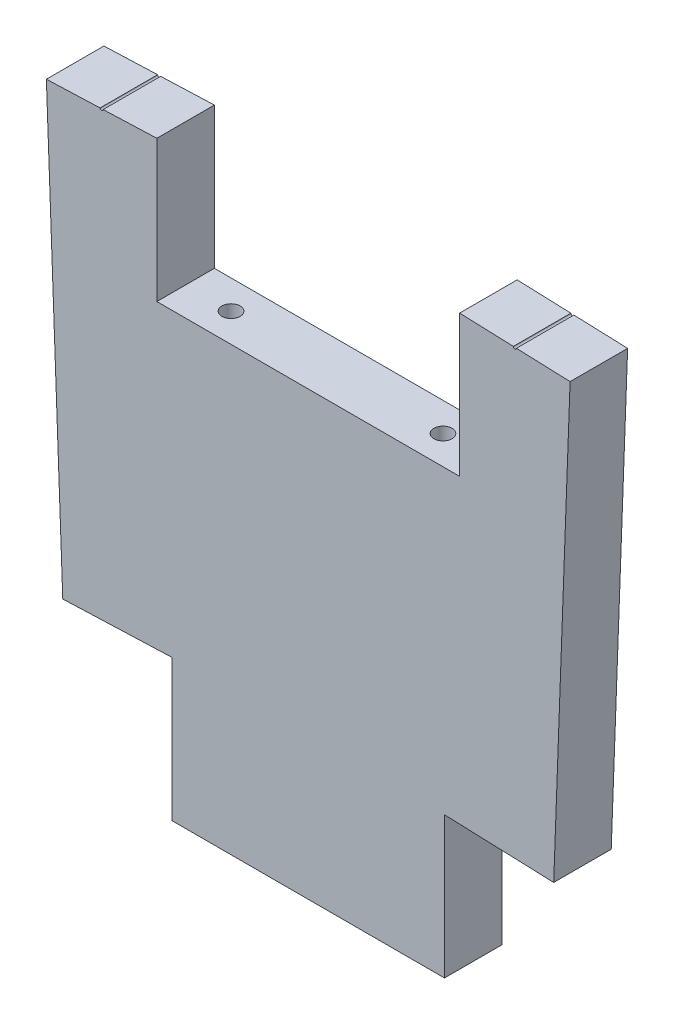
from build123d import *

# Parameters (mm, degrees)
BOSS_EXTRUDE1_DEPTH = 19
CUT_EXTRUDE1_DEPTH  = 19
SKETCH6_R           = 3
CUT_EXTRUDE2_DEPTH  = 10
SKETCH9_R           = 0.5
CUT_EXTRUDE3_DEPTH  = 20


with BuildPart() as part:
    # Sketch2 → Boss-Extrude1 (new body)
    with BuildSketch(Plane.XY):
        Polygon((-50, -12.7), (50, -12.7), (50, 34.001988406), (86.488954477, 32.648136171), (79.389661188, -158.69164437), (-79.389661188, -158.69164437), (-86.488954477, 32.648136171), (-50, 34.001988406), align=None)
    extrude(amount=-BOSS_EXTRUDE1_DEPTH)

    # Sketch4 → Cut-Extrude1 (cut)
    with BuildSketch(Plane(origin=(0, 0, -19), x_dir=(-1, 0, 0), z_dir=(0, 0, -1))):
        Polygon((176.999986596, -116.887260719), (45, -111.989655964), (45, -158.69164437), (-45, -158.69164437), (-45, -111.989655964), (-160.814787096, -116.286740127), (-160.814787096, -226.328943165), (176.999986596, -226.328943165), align=None)
    extrude(amount=-CUT_EXTRUDE1_DEPTH, mode=Mode.SUBTRACT)

    # Sketch6 → Cut-Extrude2 (cut)
    with BuildSketch(Plane(origin=(0, -12.7, 0), x_dir=(1, 0, 0), z_dir=(0, 1, 0))):
        with Locations((35, 9.5)):
            Circle(SKETCH6_R)
        with Locations((-35, 9.5)):
            Circle(SKETCH6_R)
    extrude(amount=-CUT_EXTRUDE2_DEPTH, mode=Mode.SUBTRACT)

    # Sketch9 → Cut-Extrude3 (cut)
    with BuildSketch(Plane(origin=(0, 0, -19), x_dir=(-1, 0, 0), z_dir=(0, 0, -1))):
        with Locations((68.244477239, 33.325062289)):
            Circle(SKETCH9_R)
        with Locations((-68.244477239, 33.325062289)):
            Circle(SKETCH9_R)
    extrude(amount=-CUT_EXTRUDE3_DEPTH, mode=Mode.SUBTRACT)


solid = part.part
